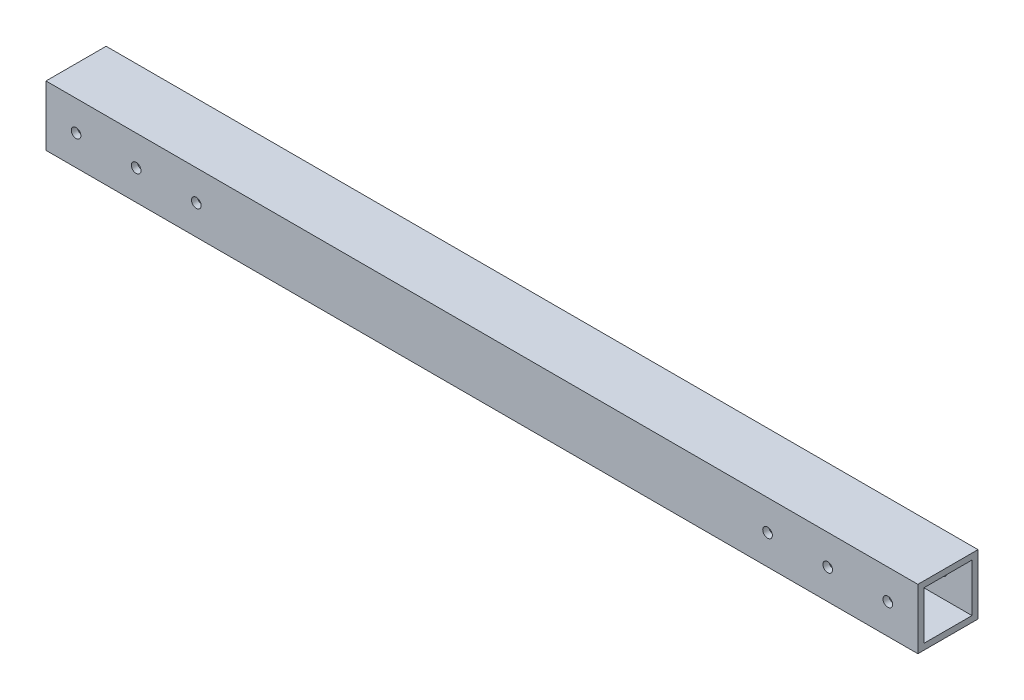
from build123d import *

# Parameters (mm, degrees)
SKETCH1_W          = 290
SKETCH1_H          = 20
EXTRUDE1_DEPTH     = 20
SKETCH2_W          = 16
SKETCH2_H          = 16
CUT_EXTRUDE1_DEPTH = 300
SKETCH4_R          = 1.6
CUT_EXTRUDE2_DEPTH = 20


with BuildPart() as part:
    # Sketch1 → Extrude1 (new body)
    with BuildSketch(Plane.XY):
        with Locations((292.497048214, 200.002006631)):
            Rectangle(SKETCH1_W, SKETCH1_H)
    extrude(amount=EXTRUDE1_DEPTH)

    # Sketch2 → Cut-Extrude1 (cut)
    with BuildSketch(Plane.ZY.offset(-147.497048214)):
        with Locations((10, 200.002006631)):
            Rectangle(SKETCH2_W, SKETCH2_H)
    extrude(amount=-CUT_EXTRUDE1_DEPTH, mode=Mode.SUBTRACT)

    # Sketch4 → Cut-Extrude2 (cut)
    with BuildSketch(Plane.XY.offset(20)):
        with Locations((427.497048214, 200.002006631)):
            Circle(SKETCH4_R)
        with Locations((407.497048214, 199.95245399)):
            Circle(SKETCH4_R)
        with Locations((387.497048214, 199.90290135)):
            Circle(SKETCH4_R)
        with Locations((197.497048214, 199.90290135)):
            Circle(SKETCH4_R)
        with Locations((177.497048214, 199.95245399)):
            Circle(SKETCH4_R)
        with Locations((157.497048214, 200.002006631)):
            Circle(SKETCH4_R)
    extrude(amount=-CUT_EXTRUDE2_DEPTH, mode=Mode.SUBTRACT)


solid = part.part
